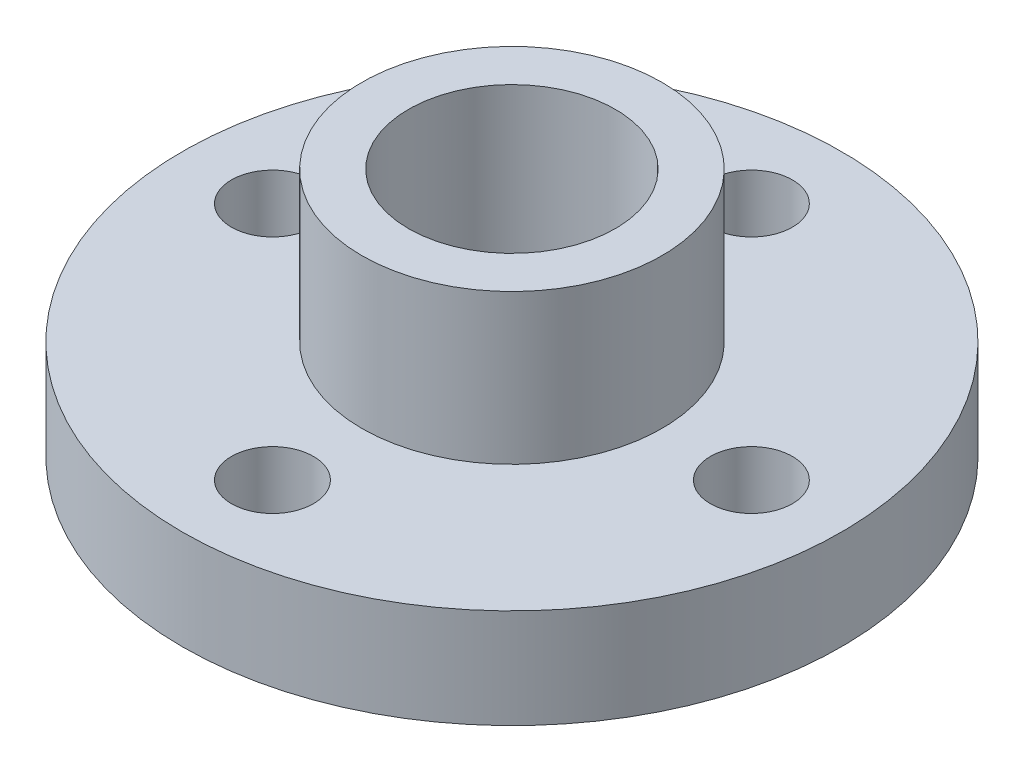
from build123d import *

# Parameters (mm, degrees)
SKETCH1_R               = 11.01
BOSS_EXTRUDE1_DEPTH     = 3.32
SKETCH3_R               = 1.37
CUT_EXTRUDE1_DEPTH      = 1
CUT_EXTRUDE1_DEPTH_BACK = 4.32
SKETCH4_R               = 5.015
BOSS_EXTRUDE2_DEPTH     = 5
SKETCH5_R               = 5.015
BOSS_EXTRUDE3_DEPTH     = 2.03
SKETCH6_R               = 3.455
CUT_EXTRUDE2_DEPTH      = 11.35


with BuildPart() as part:
    # Sketch1 → Boss-Extrude1 (new body)
    with BuildSketch(Plane(origin=(0, 0, 0), x_dir=(1, 0, 0), z_dir=(0, 1, 0))):
        Circle(SKETCH1_R)
    extrude(amount=BOSS_EXTRUDE1_DEPTH)

    # Sketch3 → Cut-Extrude1 (cut, two sides)
    with BuildSketch(Plane(origin=(0, 3.32, 0), x_dir=(1, 0, 0), z_dir=(0, 1, 0))) as cut_extrude1_sk:
        with Locations((-8, 0)):
            Circle(SKETCH3_R)
        with Locations((0, 8)):
            Circle(SKETCH3_R)
        with Locations((8, 0)):
            Circle(SKETCH3_R)
        with Locations((0, -8)):
            Circle(SKETCH3_R)
    extrude(amount=CUT_EXTRUDE1_DEPTH, mode=Mode.SUBTRACT)
    extrude(cut_extrude1_sk.sketch, amount=-CUT_EXTRUDE1_DEPTH_BACK, mode=Mode.SUBTRACT)

    # Sketch4 → Boss-Extrude2 (add)
    with BuildSketch(Plane(origin=(0, 3.32, 0), x_dir=(1, 0, 0), z_dir=(0, 1, 0))):
        Circle(SKETCH4_R)
    extrude(amount=BOSS_EXTRUDE2_DEPTH)

    # Sketch5 → Boss-Extrude3 (add)
    with BuildSketch(Plane.XZ):
        Circle(SKETCH5_R)
    extrude(amount=BOSS_EXTRUDE3_DEPTH)

    # Sketch6 → Cut-Extrude2 (cut, through all)
    with BuildSketch(Plane(origin=(0, 8.32, 0), x_dir=(1, 0, 0), z_dir=(0, 1, 0))):
        Circle(SKETCH6_R)
    extrude(amount=-CUT_EXTRUDE2_DEPTH, mode=Mode.SUBTRACT)


solid = part.part
